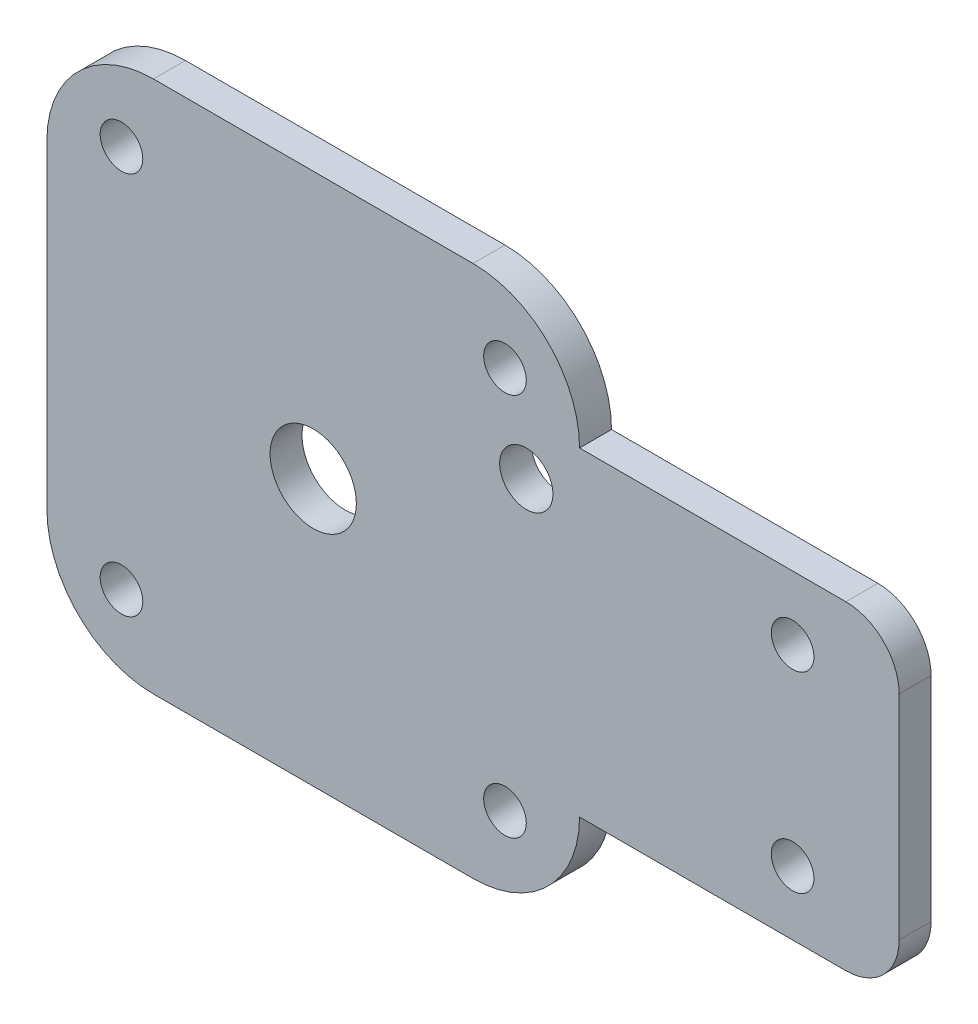
from build123d import *

# Parameters (mm, degrees)
CROQUIS1_R              = 2.5
CROQUIS1_R_2            = 4.05
CROQUIS1_R_3            = 2
SALIENTE_EXTRUIR1_DEPTH = 3


with BuildPart() as part:
    # Croquis1 → Saliente-Extruir1 (new body)
    with BuildSketch(Plane.XY):
        with BuildLine():
            ThreePointArc((0, 40), (2.928932188, 47.071067812), (10, 50))
            Line((10, 50), (40, 50))
            ThreePointArc((40, 50), (47.071067812, 47.071067812), (50, 40))
            Line((50, 40), (50, 10))
            ThreePointArc((50, 10), (47.071067812, 2.928932188), (40, 0))
            Line((40, 0), (10, 0))
            ThreePointArc((10, 0), (2.928932188, 2.928932188), (0, 10))
            Line((0, 10), (0, 40))
        make_face()
        with Locations((45, 35)):
            Circle(CROQUIS1_R, mode=Mode.SUBTRACT)
        with Locations((25, 25)):
            Circle(CROQUIS1_R_2, mode=Mode.SUBTRACT)
        with Locations((43, 43)):
            Circle(CROQUIS1_R_3, mode=Mode.SUBTRACT)
        with Locations((7, 43)):
            Circle(CROQUIS1_R_3, mode=Mode.SUBTRACT)
        with Locations((43, 7)):
            Circle(CROQUIS1_R_3, mode=Mode.SUBTRACT)
        with Locations((7, 7)):
            Circle(CROQUIS1_R_3, mode=Mode.SUBTRACT)
        with BuildLine():
            ThreePointArc((75, 40), (78.535533906, 38.535533906), (80, 35))
            Line((80, 35), (80, 15))
            ThreePointArc((80, 15), (78.535533906, 11.464466094), (75, 10))
            Line((75, 10), (50, 10))
            Line((50, 10), (50, 40))
            Line((50, 40), (75, 40))
        make_face()
        with Locations((70, 16)):
            Circle(CROQUIS1_R_3, mode=Mode.SUBTRACT)
        with Locations((70, 34)):
            Circle(CROQUIS1_R_3, mode=Mode.SUBTRACT)
    extrude(amount=SALIENTE_EXTRUIR1_DEPTH)


solid = part.part
